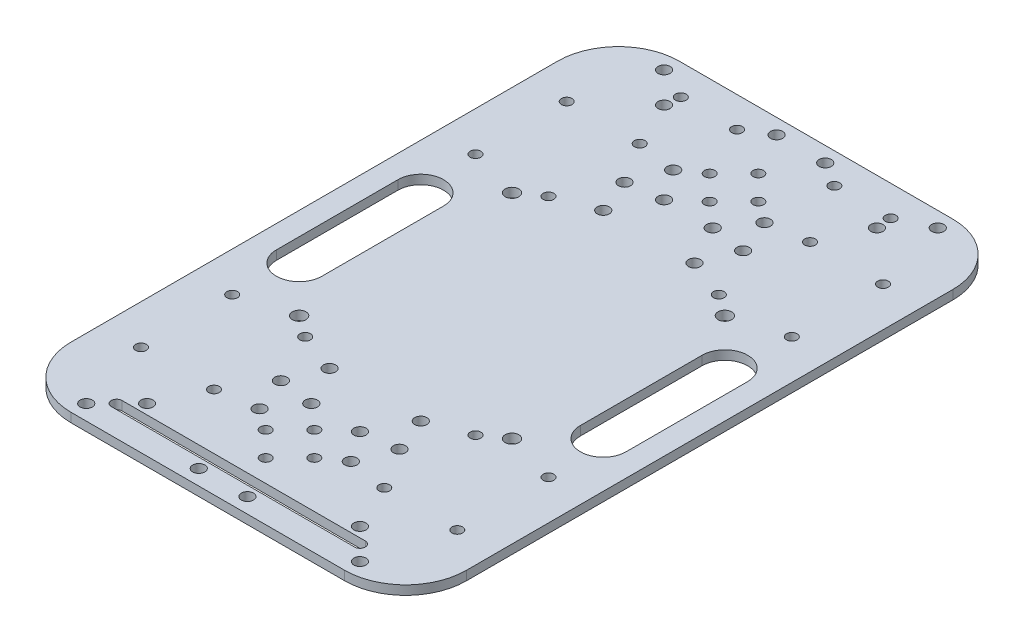
from build123d import *

# Parameters (mm, degrees)
SKETCH_1_W      = 130
SKETCH_1_H      = 200
SKETCH_1_R      = 1.75
SKETCH_1_R_2    = 2.25
SKETCH_1_R_3    = 2
EXTRUDE_2_DEPTH = 3
FILLET_1_R      = 20
FILLET_2_R      = 20
FILLET_3_R      = 20
FILLET_4_R      = 20


with BuildPart() as part:
    # 草图1 → 凸台-拉伸2 (new body)
    with BuildSketch(Plane(origin=(0, 0, 0), x_dir=(1, 0, 0), z_dir=(0, 1, 0))):
        Rectangle(SKETCH_1_W, SKETCH_1_H)
        with Locations((52, -70)):
            Circle(SKETCH_1_R, mode=Mode.SUBTRACT)
        with Locations((52, -40)):
            Circle(SKETCH_1_R, mode=Mode.SUBTRACT)
        with Locations((28, -40)):
            Circle(SKETCH_1_R, mode=Mode.SUBTRACT)
        with Locations((28, -70)):
            Circle(SKETCH_1_R, mode=Mode.SUBTRACT)
        with Locations((52, 40)):
            Circle(SKETCH_1_R, mode=Mode.SUBTRACT)
        with Locations((52, 70)):
            Circle(SKETCH_1_R, mode=Mode.SUBTRACT)
        with Locations((28, 70)):
            Circle(SKETCH_1_R, mode=Mode.SUBTRACT)
        with Locations((28, 40)):
            Circle(SKETCH_1_R, mode=Mode.SUBTRACT)
        with Locations((-28, 40)):
            Circle(SKETCH_1_R, mode=Mode.SUBTRACT)
        with Locations((-28, 70)):
            Circle(SKETCH_1_R, mode=Mode.SUBTRACT)
        with Locations((-52, 70)):
            Circle(SKETCH_1_R, mode=Mode.SUBTRACT)
        with Locations((-52, 40)):
            Circle(SKETCH_1_R, mode=Mode.SUBTRACT)
        with Locations((-28, -70)):
            Circle(SKETCH_1_R, mode=Mode.SUBTRACT)
        with Locations((-28, -40)):
            Circle(SKETCH_1_R, mode=Mode.SUBTRACT)
        with Locations((-52, -40)):
            Circle(SKETCH_1_R, mode=Mode.SUBTRACT)
        with Locations((-52, -70)):
            Circle(SKETCH_1_R, mode=Mode.SUBTRACT)
        with Locations((35, -35)):
            Circle(SKETCH_1_R_2, mode=Mode.SUBTRACT)
        with Locations((-35, -35)):
            Circle(SKETCH_1_R_2, mode=Mode.SUBTRACT)
        with Locations((-35, 35)):
            Circle(SKETCH_1_R_2, mode=Mode.SUBTRACT)
        with Locations((35, 35)):
            Circle(SKETCH_1_R_2, mode=Mode.SUBTRACT)
        with Locations((16, 90)):
            Circle(SKETCH_1_R, mode=Mode.SUBTRACT)
        with Locations((-16, 90)):
            Circle(SKETCH_1_R, mode=Mode.SUBTRACT)
        with Locations((-34.5, 90)):
            Circle(SKETCH_1_R, mode=Mode.SUBTRACT)
        with Locations((34.5, 90)):
            Circle(SKETCH_1_R, mode=Mode.SUBTRACT)
        with Locations((-8, 73)):
            Circle(SKETCH_1_R, mode=Mode.SUBTRACT)
        with Locations((0, 65)):
            Circle(SKETCH_1_R, mode=Mode.SUBTRACT)
        with Locations((0, 81)):
            Circle(SKETCH_1_R, mode=Mode.SUBTRACT)
        with Locations((8, 73)):
            Circle(SKETCH_1_R, mode=Mode.SUBTRACT)
        with Locations((-8, -73)):
            Circle(SKETCH_1_R, mode=Mode.SUBTRACT)
        with Locations((0, -81)):
            Circle(SKETCH_1_R, mode=Mode.SUBTRACT)
        with Locations((0, -65)):
            Circle(SKETCH_1_R, mode=Mode.SUBTRACT)
        with Locations((8, -73)):
            Circle(SKETCH_1_R, mode=Mode.SUBTRACT)
        with Locations((15, 45)):
            Circle(SKETCH_1_R_3, mode=Mode.SUBTRACT)
        with Locations((-15, 45)):
            Circle(SKETCH_1_R_3, mode=Mode.SUBTRACT)
        with Locations((-15, 68)):
            Circle(SKETCH_1_R_3, mode=Mode.SUBTRACT)
        with Locations((15, 68)):
            Circle(SKETCH_1_R_3, mode=Mode.SUBTRACT)
        with Locations((15, -68)):
            Circle(SKETCH_1_R_3, mode=Mode.SUBTRACT)
        with Locations((-15, -68)):
            Circle(SKETCH_1_R_3, mode=Mode.SUBTRACT)
        with Locations((-15, -45)):
            Circle(SKETCH_1_R_3, mode=Mode.SUBTRACT)
        with Locations((15, -45)):
            Circle(SKETCH_1_R_3, mode=Mode.SUBTRACT)
        with Locations((35, 85)):
            Circle(SKETCH_1_R_3, mode=Mode.SUBTRACT)
        with Locations((-35, 85)):
            Circle(SKETCH_1_R_3, mode=Mode.SUBTRACT)
        with Locations((35, -85)):
            Circle(SKETCH_1_R_3, mode=Mode.SUBTRACT)
        with Locations((-35, -85)):
            Circle(SKETCH_1_R_3, mode=Mode.SUBTRACT)
        with Locations((8, -58)):
            Circle(SKETCH_1_R_3, mode=Mode.SUBTRACT)
        with Locations((8, -95)):
            Circle(SKETCH_1_R_3, mode=Mode.SUBTRACT)
        with Locations((45, -95)):
            Circle(SKETCH_1_R_3, mode=Mode.SUBTRACT)
        with Locations((-45, -95)):
            Circle(SKETCH_1_R_3, mode=Mode.SUBTRACT)
        with Locations((-8, -95)):
            Circle(SKETCH_1_R_3, mode=Mode.SUBTRACT)
        with Locations((-8, -58)):
            Circle(SKETCH_1_R_3, mode=Mode.SUBTRACT)
        with Locations((45, 95)):
            Circle(SKETCH_1_R_3, mode=Mode.SUBTRACT)
        with Locations((8, 95)):
            Circle(SKETCH_1_R_3, mode=Mode.SUBTRACT)
        with Locations((-8, 95)):
            Circle(SKETCH_1_R_3, mode=Mode.SUBTRACT)
        with Locations((-45, 95)):
            Circle(SKETCH_1_R_3, mode=Mode.SUBTRACT)
        with Locations((8, 58)):
            Circle(SKETCH_1_R_3, mode=Mode.SUBTRACT)
        with Locations((-8, 58)):
            Circle(SKETCH_1_R_3, mode=Mode.SUBTRACT)
        with Locations((19.5, -56.5)):
            Circle(SKETCH_1_R_3, mode=Mode.SUBTRACT)
        with Locations((-19.5, -56.5)):
            Circle(SKETCH_1_R_3, mode=Mode.SUBTRACT)
        with Locations((-19.5, 56.5)):
            Circle(SKETCH_1_R_3, mode=Mode.SUBTRACT)
        with Locations((19.5, 56.5)):
            Circle(SKETCH_1_R_3, mode=Mode.SUBTRACT)
        with BuildLine():
            Line((-40, -88.25), (40, -88.25))
            ThreePointArc((40, -88.25), (41.75, -90), (40, -91.75))
            Line((40, -91.75), (-40, -91.75))
            ThreePointArc((-40, -91.75), (-41.75, -90), (-40, -88.25))
        make_face(mode=Mode.SUBTRACT)
        with BuildLine():
            Line((42.5, -20), (42.5, 20))
            ThreePointArc((42.5, 20), (50, 27.5), (57.5, 20))
            Line((57.5, 20), (57.5, -20))
            ThreePointArc((57.5, -20), (50, -27.5), (42.5, -20))
        make_face(mode=Mode.SUBTRACT)
        with BuildLine():
            Line((-57.5, -20), (-57.5, 20))
            ThreePointArc((-57.5, 20), (-50, 27.5), (-42.5, 20))
            Line((-42.5, 20), (-42.5, -20))
            ThreePointArc((-42.5, -20), (-50, -27.5), (-57.5, -20))
        make_face(mode=Mode.SUBTRACT)
    extrude(amount=EXTRUDE_2_DEPTH)

    # 圆角1
    fillet_1_edges = [part.edges().sort_by_distance(p)[0] for p in [
        (65, 1.5, 100),
    ]]
    fillet(fillet_1_edges, radius=FILLET_1_R)

    # 圆角2
    fillet_2_edges = [part.edges().sort_by_distance(p)[0] for p in [
        (-65, 1.5, 100),
    ]]
    fillet(fillet_2_edges, radius=FILLET_2_R)

    # 圆角3
    fillet_3_edges = [part.edges().sort_by_distance(p)[0] for p in [
        (-65, 1.5, -100),
    ]]
    fillet(fillet_3_edges, radius=FILLET_3_R)

    # 圆角4
    fillet_4_edges = [part.edges().sort_by_distance(p)[0] for p in [
        (65, 1.5, -100),
    ]]
    fillet(fillet_4_edges, radius=FILLET_4_R)


solid = part.part
